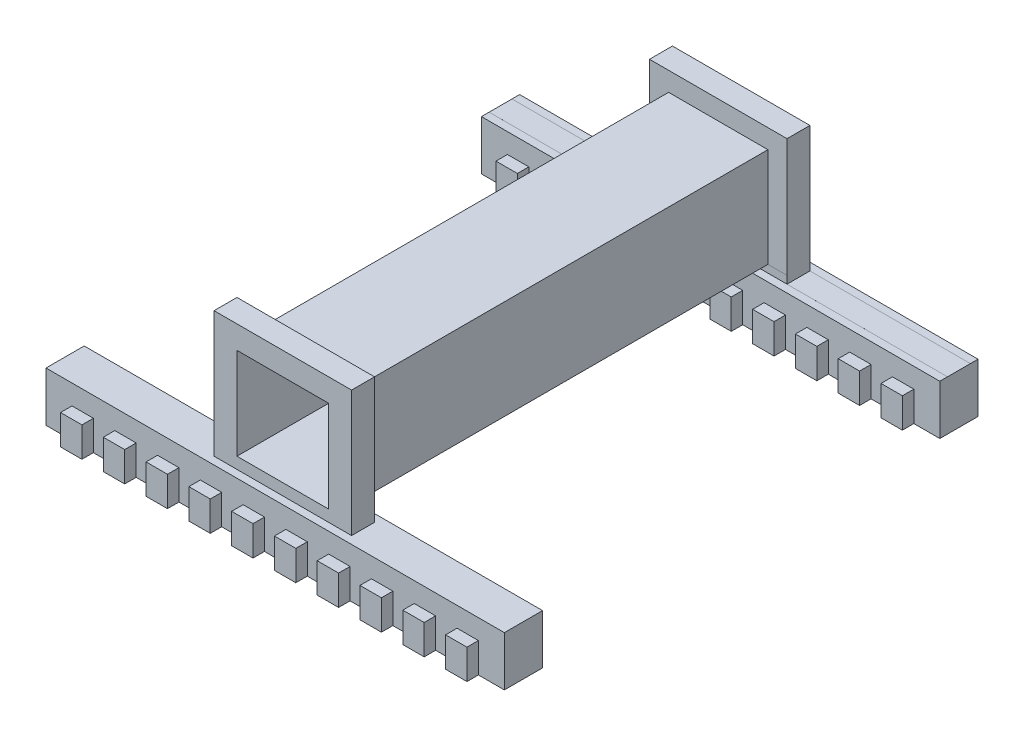
from build123d import *

# Parameters (mm, degrees)
SKETCH_1_W           = 13
SKETCH_1_H           = 13
EXTRUDE_1_DEPTH      = 30
SKETCH_2_W           = 12
SKETCH_2_H           = 12
CUT_EXTRUDE_2_DEPTH  = 60
SKETCH_4_W           = 18
SKETCH_4_H           = 17.852467707
EXTRUDE_2_DEPTH      = 3
SKETCH_6_W           = 12
SKETCH_6_H           = 12
CUT_EXTRUDE_3_DEPTH  = 3
SKETCH_9_W           = 18
SKETCH_9_H           = 18
SKETCH_9_W_2         = 12
SKETCH_9_H_2         = 12
EXTRUDE_3_DEPTH      = 3
SKETCH_10_W          = 49
SKETCH_10_H          = 6
CUT_EXTRUDE_4_DEPTH  = 60
SKETCH_13_W          = 6
SKETCH_13_H          = 6
EXTRUDE_4_DEPTH      = 60
SKETCH_14_W          = 3.5
SKETCH_14_H          = 6
CUT_EXTRUDE_5_DEPTH  = 60
SKETCH_15_W          = 2.5
SKETCH_15_H          = 6
EXTRUDE_5_DEPTH      = 60
SKETCH_16_W          = 8
SKETCH_16_H          = 1.5
EXTRUDE_6_DEPTH      = 60
SKETCH_17_W          = 8
SKETCH_17_H          = 1.5
EXTRUDE_7_DEPTH      = 60
SKETCH_18_W          = 2.5
SKETCH_18_H          = 1
CUT_EXTRUDE_6_DEPTH  = 60
SKETCH_21_W          = 2.5
SKETCH_21_H          = 1
CUT_EXTRUDE_7_DEPTH  = 60
CUT_EXTRUDE_9_DEPTH  = 1
SKETCH_25_W          = 21
SKETCH_25_H          = 3
CUT_EXTRUDE_10_DEPTH = 1
SKETCH_26_W          = 2.5
SKETCH_26_H          = 1.000446107
SKETCH_26_W_2        = 2.50456935
CUT_EXTRUDE_11_DEPTH = 60
SKETCH_27_W          = 21
SKETCH_27_H          = 2.99543065
CUT_EXTRUDE_12_DEPTH = 1
CUT_EXTRUDE_14_DEPTH = 1.5
CUT_EXTRUDE_15_DEPTH = 1.5
CUT_EXTRUDE_16_DEPTH = 1.5
CUT_EXTRUDE_17_DEPTH = 1.5


with BuildPart() as part:
    # 草图1 → 凸台-拉伸1 (new body, symmetric)
    with BuildSketch(Plane.XY):
        Polygon((-30, -6.5), (-30, -12.5), (30, -12.5), (30, -6.5), (6.5, -6.5), (-6.5, -6.5), align=None)
        Rectangle(SKETCH_1_W, SKETCH_1_H)
    extrude(amount=EXTRUDE_1_DEPTH, both=True)

    # 草图2 → 切除-拉伸2 (cut)
    with BuildSketch(Plane.XY.offset(30)):
        Rectangle(SKETCH_2_W, SKETCH_2_H)
    extrude(amount=-CUT_EXTRUDE_2_DEPTH, mode=Mode.SUBTRACT)

    # 草图4 → 凸台-拉伸2 (add)
    with BuildSketch(Plane.XY.offset(30)):
        with Locations((0, 0.073766146)):
            Rectangle(SKETCH_4_W, SKETCH_4_H)
    extrude(amount=-EXTRUDE_2_DEPTH)

    # 草图6 → 切除-拉伸3 (cut)
    with BuildSketch(Plane(origin=(0, 0, 27), x_dir=(-1, 0, 0), z_dir=(0, 0, -1))):
        Rectangle(SKETCH_6_W, SKETCH_6_H)
    extrude(amount=-CUT_EXTRUDE_3_DEPTH, mode=Mode.SUBTRACT)

    # 草图9 → 凸台-拉伸3 (add)
    with BuildSketch(Plane(origin=(0, 0, -30), x_dir=(-1, 0, 0), z_dir=(0, 0, -1))):
        Rectangle(SKETCH_9_W, SKETCH_9_H)
        Rectangle(SKETCH_9_W_2, SKETCH_9_H_2, mode=Mode.SUBTRACT)
    extrude(amount=-EXTRUDE_3_DEPTH)

    # 草图10 → 切除-拉伸4 (cut)
    with BuildSketch(Plane(origin=(30, 0, 0), x_dir=(0, 0, -1), z_dir=(1, 0, 0))):
        with Locations((0, -9.5)):
            Rectangle(SKETCH_10_W, SKETCH_10_H)
    extrude(amount=-CUT_EXTRUDE_4_DEPTH, mode=Mode.SUBTRACT)

    # 草图13 → 凸台-拉伸4 (add)
    with BuildSketch(Plane(origin=(30, 0, 0), x_dir=(0, 0, -1), z_dir=(1, 0, 0))):
        with Locations((-33, -9.5)):
            Rectangle(SKETCH_13_W, SKETCH_13_H)
    extrude(amount=-EXTRUDE_4_DEPTH)

    # 草图14 → 切除-拉伸5 (cut)
    with BuildSketch(Plane(origin=(30, 0, 0), x_dir=(0, 0, -1), z_dir=(1, 0, 0))):
        with Locations((-34.25, -9.5)):
            Rectangle(SKETCH_14_W, SKETCH_14_H)
    extrude(amount=-CUT_EXTRUDE_5_DEPTH, mode=Mode.SUBTRACT)

    # 草图15 → 凸台-拉伸5 (add)
    with BuildSketch(Plane(origin=(30, 0, 0), x_dir=(0, 0, -1), z_dir=(1, 0, 0))):
        with Locations((31.25, -9.5)):
            Rectangle(SKETCH_15_W, SKETCH_15_H)
    extrude(amount=-EXTRUDE_5_DEPTH)

    # 草图16 → 凸台-拉伸6 (add)
    with BuildSketch(Plane.ZY.offset(30)):
        with Locations((-28.5, -13.25)):
            Rectangle(SKETCH_16_W, SKETCH_16_H)
    extrude(amount=-EXTRUDE_6_DEPTH)

    # 草图17 → 凸台-拉伸7 (add)
    with BuildSketch(Plane.ZY.offset(30)):
        with Locations((28.5, -13.25)):
            Rectangle(SKETCH_17_W, SKETCH_17_H)
    extrude(amount=-EXTRUDE_7_DEPTH)

    # 草图18 → 切除-拉伸6 (cut)
    with BuildSketch(Plane.ZY.offset(30)):
        with Locations((31.25, -7)):
            Rectangle(SKETCH_18_W, SKETCH_18_H)
    extrude(amount=-CUT_EXTRUDE_6_DEPTH, mode=Mode.SUBTRACT)

    # 草图21 → 切除-拉伸7 (cut)
    with BuildSketch(Plane.ZY.offset(30)):
        with Locations((25.75, -7)):
            Rectangle(SKETCH_21_W, SKETCH_21_H)
    extrude(amount=-CUT_EXTRUDE_7_DEPTH, mode=Mode.SUBTRACT)

    # 草图24 → 切除-拉伸9 (cut)
    with BuildSketch(Plane(origin=(0, -6.5, 0), x_dir=(1, 0, 0), z_dir=(0, 1, 0))):
        Polygon((-9, -27), (-30, -27), (-30, -30.05851099), (-9, -30), align=None)
    extrude(amount=-CUT_EXTRUDE_9_DEPTH, mode=Mode.SUBTRACT)

    # 草图25 → 切除-拉伸10 (cut)
    with BuildSketch(Plane(origin=(0, -6.5, 0), x_dir=(1, 0, 0), z_dir=(0, 1, 0))):
        with Locations((19.5, -28.5)):
            Rectangle(SKETCH_25_W, SKETCH_25_H)
    extrude(amount=-CUT_EXTRUDE_10_DEPTH, mode=Mode.SUBTRACT)

    # 草图26 → 切除-拉伸11 (cut)
    with BuildSketch(Plane(origin=(30, 0, 0), x_dir=(0, 0, -1), z_dir=(1, 0, 0))):
        with Locations((31.25, -7.000223054)):
            Rectangle(SKETCH_26_W, SKETCH_26_H)
        with Locations((25.752284675, -7.000223054)):
            Rectangle(SKETCH_26_W_2, SKETCH_26_H)
    extrude(amount=-CUT_EXTRUDE_11_DEPTH, mode=Mode.SUBTRACT)

    # 草图27 → 切除-拉伸12 (cut)
    with BuildSketch(Plane(origin=(0, -6.5, 0), x_dir=(1, 0, 0), z_dir=(0, 1, 0))):
        with Locations((19.5, 28.502284675)):
            Rectangle(SKETCH_27_W, SKETCH_27_H)
        with Locations((-19.5, 28.502284675)):
            Rectangle(SKETCH_27_W, SKETCH_27_H)
    extrude(amount=-CUT_EXTRUDE_12_DEPTH, mode=Mode.SUBTRACT)

    # 草图28 → 切除-拉伸14 (cut)
    with BuildSketch(Plane.XY.offset(32.5)):
        Polygon((-30, -7.5), (-30, -14), (-26.6, -14), (-26.6, -10.09562628), (-23.8, -10.09562628), (-23.8, -14), (-21, -14), (-21, -10.09562628), (-18.2, -10.09562628), (-18.2, -14), (-15.4, -14), (-15.4, -10.09562628), (-12.6, -10.09562628), (-12.6, -14), (-9.8, -14), (-9.8, -10.09562628), (-7, -10.09562628), (-7, -14), (-4.2, -14), (-4.2, -10.09562628), (-1.400068469, -10.09562628), (-1.400068469, -14), (1.399931531, -14), (1.399931531, -10.09562628), (4.199658105, -10.09562628), (4.199658105, -14), (6.999658105, -14), (6.999658105, -10.09562628), (9.799658105, -10.09562628), (9.799658105, -14), (12.599658105, -14), (12.599658105, -10.09562628), (15.403708996, -10.09562628), (15.403708996, -14), (18.202545098, -14), (18.202545098, -10.09562628), (21.002545098, -10.09562628), (21.002545098, -14), (23.804045978, -14), (23.804045978, -10.09562628), (26.602591134, -10.09562628), (26.602591134, -14), (30, -14), (30, -10.09562628), (30, -7.5), align=None)
    extrude(amount=-CUT_EXTRUDE_14_DEPTH, mode=Mode.SUBTRACT)

    # 草图29 → 切除-拉伸15 (cut)
    with BuildSketch(Plane(origin=(0, 0, 24.5), x_dir=(-1, 0, 0), z_dir=(0, 0, -1))):
        Polygon((26.6, -14), (30, -14), (30, -7.5), (-30, -7.5), (-30, -14), (-26.602591134, -14), (-26.602591134, -10.09562628), (-23.804045978, -10.09562628), (-23.804045978, -14), (-21.002545098, -14), (-21.002545098, -10.09562628), (-18.202545098, -10.09562628), (-18.202545098, -14), (-15.403708996, -14), (-15.403708996, -10.09562628), (-12.599658105, -10.09562628), (-12.599658105, -14), (-9.799658105, -14), (-9.799658105, -10.09562628), (-6.999658105, -10.09562628), (-6.999658105, -14), (-4.199658105, -14), (-4.199658105, -10.09562628), (-1.399931531, -10.09562628), (-1.399931531, -14), (1.400068469, -14), (1.400068469, -10.09562628), (4.2, -10.09562628), (4.2, -14), (7, -14), (7, -10.09562628), (9.8, -10.09562628), (9.8, -14), (12.6, -14), (12.6, -10.09562628), (15.4, -10.09562628), (15.4, -14), (18.2, -14), (18.2, -10.09562628), (21, -10.09562628), (21, -14), (23.8, -14), (23.8, -10.09562628), (26.6, -10.09562628), align=None)
    extrude(amount=-CUT_EXTRUDE_15_DEPTH, mode=Mode.SUBTRACT)

    # 草图31 → 切除-拉伸16 (cut)
    with BuildSketch(Plane(origin=(0, 0, -32.5), x_dir=(-1, 0, 0), z_dir=(0, 0, -1))):
        Polygon((30, -14), (30, -7.500446107), (-30, -7.500446107), (-30, -14), (-26.602591134, -14), (-26.602591134, -10.09562628), (-23.804045978, -10.09562628), (-23.804045978, -14), (-21.002545098, -14), (-21.002545098, -10.09562628), (-18.202545098, -10.09562628), (-18.202545098, -14), (-15.403708996, -14), (-15.403708996, -10.09562628), (-12.599658105, -10.09562628), (-12.599658105, -14), (-9.799658105, -14), (-9.799658105, -10.09562628), (-6.999658105, -10.09562628), (-6.999658105, -14), (-4.199658105, -14), (-4.199658105, -10.09562628), (-1.399931531, -10.09562628), (-1.399931531, -14), (1.400068469, -14), (1.400068469, -10.09562628), (4.2, -10.09562628), (4.2, -14), (7, -14), (7, -10.09562628), (9.8, -10.09562628), (9.8, -14), (12.6, -14), (12.6, -10.09562628), (15.4, -10.09562628), (15.4, -14), (18.2, -14), (18.2, -10.09562628), (21, -10.09562628), (21, -14), (23.8, -14), (23.8, -10.09562628), (26.6, -10.09562628), (26.6, -14), align=None)
    extrude(amount=-CUT_EXTRUDE_16_DEPTH, mode=Mode.SUBTRACT)

    # 草图30 → 切除-拉伸17 (cut)
    with BuildSketch(Plane.XY.offset(-24.5)):
        Polygon((26.602591134, -14), (30, -14), (30, -7.500446107), (-30, -7.500446107), (-30, -14), (-26.6, -14), (-26.6, -10.09562628), (-23.8, -10.09562628), (-23.8, -14), (-21, -14), (-21, -10.09562628), (-18.2, -10.09562628), (-18.2, -14), (-15.4, -14), (-15.4, -10.09562628), (-12.6, -10.09562628), (-12.6, -14), (-9.8, -14), (-9.8, -10.09562628), (-7, -10.09562628), (-7, -14), (-4.2, -14), (-4.2, -10.09562628), (-1.400068469, -10.09562628), (-1.400068469, -14), (1.399931531, -14), (1.399931531, -10.09562628), (4.199658105, -10.09562628), (4.199658105, -14), (6.999658105, -14), (6.999658105, -10.09562628), (9.799658105, -10.09562628), (9.799658105, -14), (12.599658105, -14), (12.599658105, -10.09562628), (15.403708996, -10.09562628), (15.403708996, -14), (18.202545098, -14), (18.202545098, -10.09562628), (21.002545098, -10.09562628), (21.002545098, -14), (23.804045978, -14), (23.804045978, -10.09562628), (26.602591134, -10.09562628), align=None)
    extrude(amount=-CUT_EXTRUDE_17_DEPTH, mode=Mode.SUBTRACT)


solid = part.part
